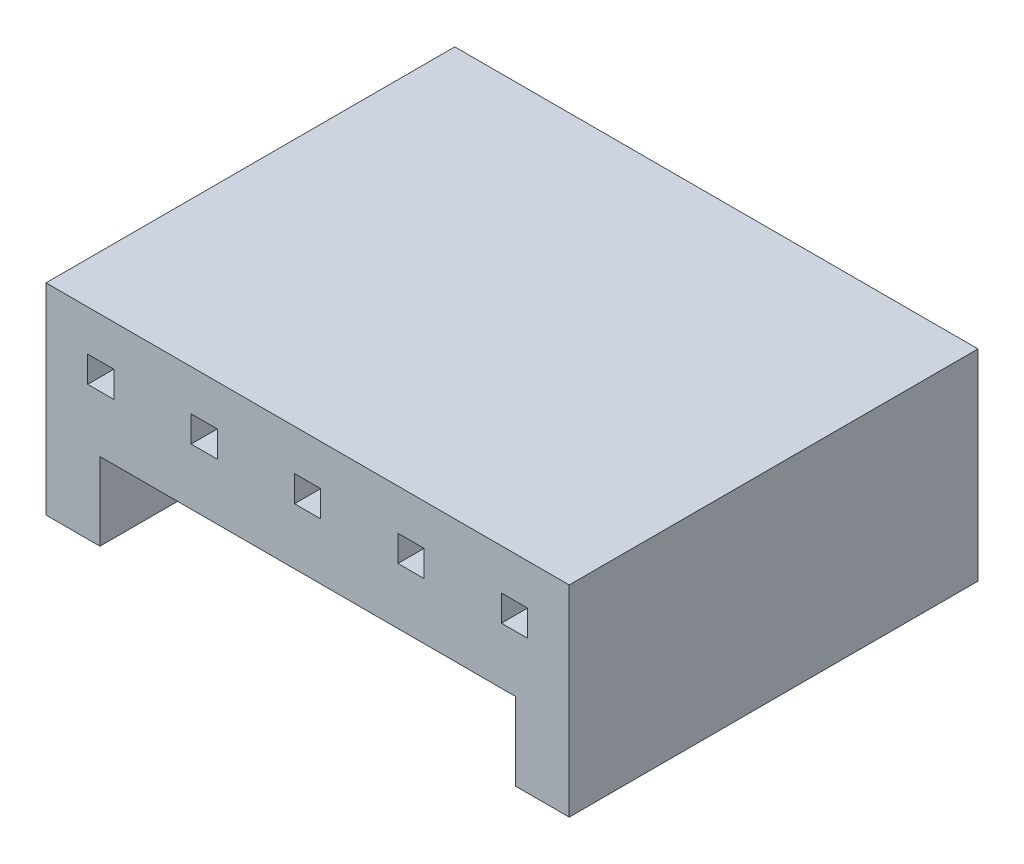
from build123d import *

# Parameters (mm, degrees)
SKETCH1_W           = 12.8
SKETCH1_H           = 4.92
BOSS_EXTRUDE1_DEPTH = 10
SKETCH2_W           = 0.64
SKETCH2_H           = 0.64
SKETCH2_W_2         = 10.16
SKETCH2_H_2         = 1.9
CUT_EXTRUDE1_DEPTH  = 11


with BuildPart() as part:
    # Sketch1 → Boss-Extrude1 (new body)
    with BuildSketch(Plane.XY):
        with Locations((6.4, 2.46)):
            Rectangle(SKETCH1_W, SKETCH1_H)
    extrude(amount=BOSS_EXTRUDE1_DEPTH)

    # Sketch2 → Cut-Extrude1 (cut, through all)
    with BuildSketch(Plane.XY.offset(10)):
        with Locations((1.34, 3.6)):
            Rectangle(SKETCH2_W, SKETCH2_H)
        with Locations((3.87, 3.6)):
            Rectangle(SKETCH2_W, SKETCH2_H)
        with Locations((6.4, 3.6)):
            Rectangle(SKETCH2_W, SKETCH2_H)
        with Locations((8.93, 3.6)):
            Rectangle(SKETCH2_W, SKETCH2_H)
        with Locations((11.46, 3.6)):
            Rectangle(SKETCH2_W, SKETCH2_H)
        with Locations((6.4, 0.95)):
            Rectangle(SKETCH2_W_2, SKETCH2_H_2)
    extrude(amount=-CUT_EXTRUDE1_DEPTH, mode=Mode.SUBTRACT)


solid = part.part
